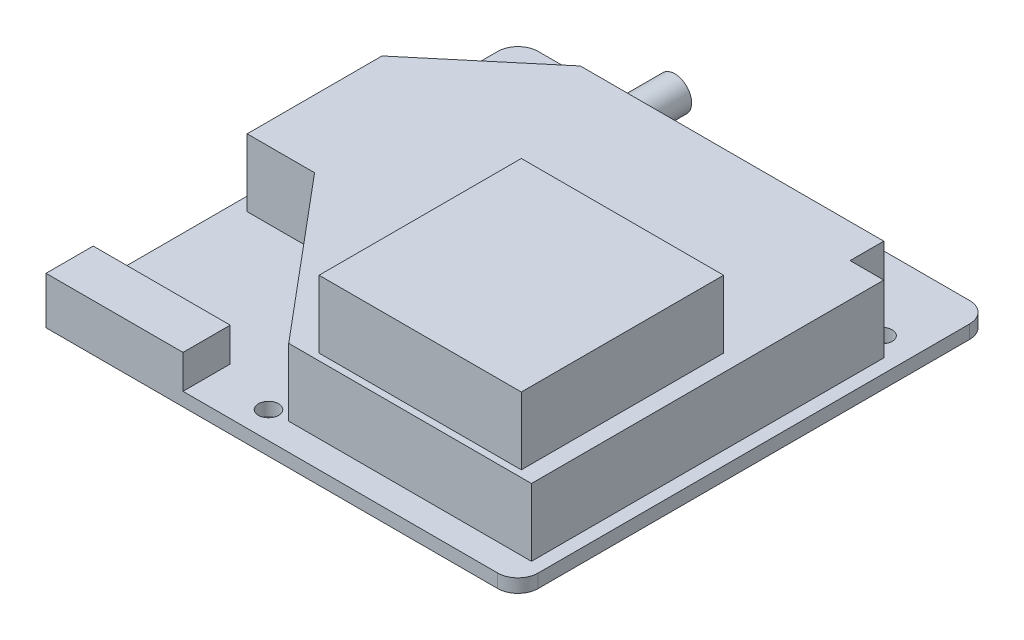
from build123d import *

# Parameters (mm, degrees)
SKIZZE1_W                       = 70
SKIZZE1_H                       = 70
SKIZZE1_R                       = 1.5
AUFSATZ_LINEAR_AUSTRAGEN1_DEPTH = 2
SKIZZE2_W                       = 20.32
SKIZZE2_H                       = 7
AUFSATZ_LINEAR_AUSTRAGEN2_DEPTH = 5
AUFSATZ_LINEAR_AUSTRAGEN3_DEPTH = 10
SKIZZE4_W                       = 30
SKIZZE4_H                       = 30
AUFSATZ_LINEAR_AUSTRAGEN4_DEPTH = 10
SKIZZE5_R                       = 2.5
SKIZZE5_R_2                     = 1.5
AUFSATZ_LINEAR_AUSTRAGEN5_DEPTH = 10
SKIZZE6_W                       = 25
SKIZZE6_H                       = 25
AUFSATZ_LINEAR_AUSTRAGEN6_DEPTH = 3.5
VERRUNDUNG1_R                   = 3


with BuildPart() as part:
    # Skizze1 → Aufsatz-Linear austragen1 (new body)
    with BuildSketch(Plane(origin=(0, 0, 0), x_dir=(1, 0, 0), z_dir=(0, 1, 0))):
        Rectangle(SKIZZE1_W, SKIZZE1_H)
        with Locations((-6, -31)):
            Circle(SKIZZE1_R, mode=Mode.SUBTRACT)
        with Locations((-30, 24)):
            Circle(SKIZZE1_R, mode=Mode.SUBTRACT)
        with Locations((30, 24)):
            Circle(SKIZZE1_R, mode=Mode.SUBTRACT)
    extrude(amount=AUFSATZ_LINEAR_AUSTRAGEN1_DEPTH)

    # Skizze2 → Aufsatz-Linear austragen2 (add)
    with BuildSketch(Plane(origin=(0, 2, 0), x_dir=(1, 0, 0), z_dir=(0, 1, 0))):
        with Locations((-24.84, -31.5)):
            Rectangle(SKIZZE2_W, SKIZZE2_H)
    extrude(amount=AUFSATZ_LINEAR_AUSTRAGEN2_DEPTH)

    # Skizze3 → Aufsatz-Linear austragen3 (add)
    with BuildSketch(Plane(origin=(0, 2, 0), x_dir=(1, 0, 0), z_dir=(0, 1, 0))):
        Polygon((-33, -7.164928148), (-23, -7.164928148), (-3, -31), (33, -31), (33, 21.260665951), (28, 21.260665951), (28, 26.260665951), (-17, 26.260665951), (-33, 12.835071852), align=None)
    extrude(amount=AUFSATZ_LINEAR_AUSTRAGEN3_DEPTH)

    # Skizze4 → Aufsatz-Linear austragen4 (add)
    with BuildSketch(Plane(origin=(0, 12, 0), x_dir=(1, 0, 0), z_dir=(0, 1, 0))):
        with Locations((15.5, -15)):
            Rectangle(SKIZZE4_W, SKIZZE4_H)
    extrude(amount=AUFSATZ_LINEAR_AUSTRAGEN4_DEPTH)

    # Skizze5 → Aufsatz-Linear austragen5 (add)
    with BuildSketch(Plane(origin=(0, 0, -26.260665951), x_dir=(-1, 0, 0), z_dir=(0, 0, -1))):
        with Locations((13, 5.5)):
            Circle(SKIZZE5_R)
        with Locations((13, 5.5)):
            Circle(SKIZZE5_R_2, mode=Mode.SUBTRACT)
    extrude(amount=AUFSATZ_LINEAR_AUSTRAGEN5_DEPTH)

    # Skizze6 → Aufsatz-Linear austragen6 (add)
    with BuildSketch(Plane.XZ):
        with Locations((-14.5, -12.5)):
            Rectangle(SKIZZE6_W, SKIZZE6_H)
    extrude(amount=AUFSATZ_LINEAR_AUSTRAGEN6_DEPTH)

    # Verrundung1
    verrundung1_edges = [part.edges().sort_by_distance(p)[0] for p in [
        (-35, 1, -35),
        (35, 1, -35),
        (35, 1, 35),
    ]]
    fillet(verrundung1_edges, radius=VERRUNDUNG1_R)


solid = part.part
